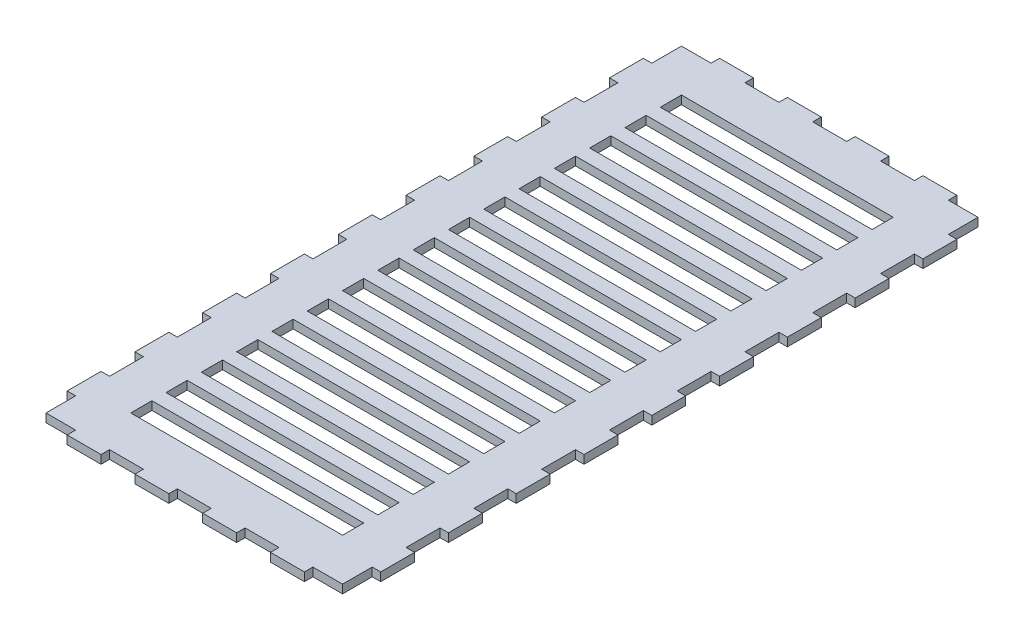
from build123d import *

# Parameters (mm, degrees)
SKETCH1_W           = 210
SKETCH1_H           = 450
SKETCH1_W_2         = 150
SKETCH1_H_2         = 15
BOSS_EXTRUDE1_DEPTH = 6
SKETCH3_W           = 6
SKETCH3_H           = 24
BOSS_EXTRUDE3_DEPTH = 6
SKETCH2_W           = 24
SKETCH2_H           = 6
BOSS_EXTRUDE4_DEPTH = 6


with BuildPart() as part:
    # Sketch1 → Boss-Extrude1 (new body)
    with BuildSketch(Plane(origin=(0, 0, 0), x_dir=(1, 0, 0), z_dir=(0, 1, 0))):
        Rectangle(SKETCH1_W, SKETCH1_H)
        with Locations((0, -162.5)):
            Rectangle(SKETCH1_W_2, SKETCH1_H_2, mode=Mode.SUBTRACT)
        with Locations((0, -187.5)):
            Rectangle(SKETCH1_W_2, SKETCH1_H_2, mode=Mode.SUBTRACT)
        with Locations((0, -137.5)):
            Rectangle(SKETCH1_W_2, SKETCH1_H_2, mode=Mode.SUBTRACT)
        with Locations((0, -112.5)):
            Rectangle(SKETCH1_W_2, SKETCH1_H_2, mode=Mode.SUBTRACT)
        with Locations((0, -87.5)):
            Rectangle(SKETCH1_W_2, SKETCH1_H_2, mode=Mode.SUBTRACT)
        with Locations((0, -62.5)):
            Rectangle(SKETCH1_W_2, SKETCH1_H_2, mode=Mode.SUBTRACT)
        with Locations((0, -37.5)):
            Rectangle(SKETCH1_W_2, SKETCH1_H_2, mode=Mode.SUBTRACT)
        with Locations((0, -12.5)):
            Rectangle(SKETCH1_W_2, SKETCH1_H_2, mode=Mode.SUBTRACT)
        with Locations((0, 12.5)):
            Rectangle(SKETCH1_W_2, SKETCH1_H_2, mode=Mode.SUBTRACT)
        with Locations((0, 37.5)):
            Rectangle(SKETCH1_W_2, SKETCH1_H_2, mode=Mode.SUBTRACT)
        with Locations((0, 62.5)):
            Rectangle(SKETCH1_W_2, SKETCH1_H_2, mode=Mode.SUBTRACT)
        with Locations((0, 87.5)):
            Rectangle(SKETCH1_W_2, SKETCH1_H_2, mode=Mode.SUBTRACT)
        with Locations((0, 112.5)):
            Rectangle(SKETCH1_W_2, SKETCH1_H_2, mode=Mode.SUBTRACT)
        with Locations((0, 137.5)):
            Rectangle(SKETCH1_W_2, SKETCH1_H_2, mode=Mode.SUBTRACT)
        with Locations((0, 162.5)):
            Rectangle(SKETCH1_W_2, SKETCH1_H_2, mode=Mode.SUBTRACT)
        with Locations((0, 187.5)):
            Rectangle(SKETCH1_W_2, SKETCH1_H_2, mode=Mode.SUBTRACT)
    extrude(amount=BOSS_EXTRUDE1_DEPTH)

    # Sketch3 → Boss-Extrude3 (add)
    with BuildSketch(Plane(origin=(0, 6, 0), x_dir=(1, 0, 0), z_dir=(0, 1, 0))):
        with Locations((-108, 192)):
            Rectangle(SKETCH3_W, SKETCH3_H)
        with Locations((108, 192)):
            Rectangle(SKETCH3_W, SKETCH3_H)
        with Locations((108, 144)):
            Rectangle(SKETCH3_W, SKETCH3_H)
        with Locations((108, 96)):
            Rectangle(SKETCH3_W, SKETCH3_H)
        with Locations((108, 48)):
            Rectangle(SKETCH3_W, SKETCH3_H)
        with Locations((108, 0)):
            Rectangle(SKETCH3_W, SKETCH3_H)
        with Locations((108, -48)):
            Rectangle(SKETCH3_W, SKETCH3_H)
        with Locations((108, -96)):
            Rectangle(SKETCH3_W, SKETCH3_H)
        with Locations((108, -144)):
            Rectangle(SKETCH3_W, SKETCH3_H)
        with Locations((108, -192)):
            Rectangle(SKETCH3_W, SKETCH3_H)
        with Locations((-108, 144)):
            Rectangle(SKETCH3_W, SKETCH3_H)
        with Locations((-108, 96)):
            Rectangle(SKETCH3_W, SKETCH3_H)
        with Locations((-108, 48)):
            Rectangle(SKETCH3_W, SKETCH3_H)
        with Locations((-108, 0)):
            Rectangle(SKETCH3_W, SKETCH3_H)
        with Locations((-108, -48)):
            Rectangle(SKETCH3_W, SKETCH3_H)
        with Locations((-108, -96)):
            Rectangle(SKETCH3_W, SKETCH3_H)
        with Locations((-108, -144)):
            Rectangle(SKETCH3_W, SKETCH3_H)
        with Locations((-108, -192)):
            Rectangle(SKETCH3_W, SKETCH3_H)
    extrude(amount=-BOSS_EXTRUDE3_DEPTH)

    # Sketch2 → Boss-Extrude4 (add)
    with BuildSketch(Plane(origin=(0, 6, 0), x_dir=(1, 0, 0), z_dir=(0, 1, 0))):
        with Locations((-72, 228)):
            Rectangle(SKETCH2_W, SKETCH2_H)
        with Locations((-24, 228)):
            Rectangle(SKETCH2_W, SKETCH2_H)
        with Locations((24, 228)):
            Rectangle(SKETCH2_W, SKETCH2_H)
        with Locations((72, 228)):
            Rectangle(SKETCH2_W, SKETCH2_H)
        with Locations((-72, -228)):
            Rectangle(SKETCH2_W, SKETCH2_H)
        with Locations((-24, -228)):
            Rectangle(SKETCH2_W, SKETCH2_H)
        with Locations((24, -228)):
            Rectangle(SKETCH2_W, SKETCH2_H)
        with Locations((72, -228)):
            Rectangle(SKETCH2_W, SKETCH2_H)
    extrude(amount=-BOSS_EXTRUDE4_DEPTH)


solid = part.part
